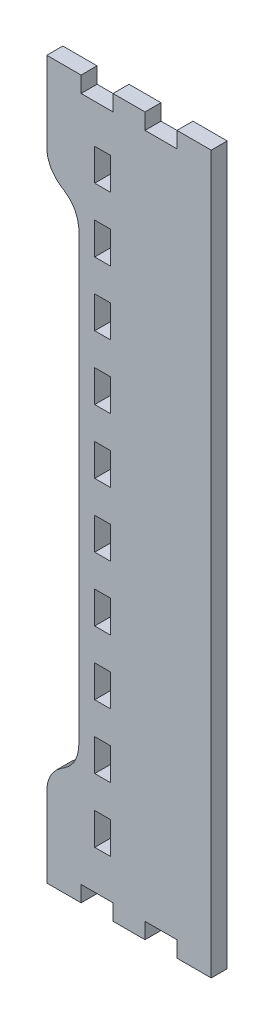
from build123d import *

# Parameters (mm, degrees)
BOSS_EXTRUDE1_DEPTH = 5.715


with BuildPart() as part:
    # Model → Boss-Extrude1 (new body)
    with BuildSketch(Plane.XY):
        Polygon((863.26218, 23.2006394), (875.52784, 23.2006394), (875.52784, 28.91536), (886.95784, 28.91536), (886.95784, 23.2006394), (898.38784, 23.2006394), (898.38784, 28.91536), (909.81784, 28.91536), (909.81784, 23.2006394), (922.08096, 23.2006394), (922.08096, 279.63114), (909.81784, 279.63114), (909.81784, 273.91614), (898.38784, 273.91614), (898.38784, 279.63114), (886.95784, 279.63114), (886.95784, 273.91614), (875.52784, 273.91614), (875.52784, 279.63114), (863.26218, 279.63114), (863.26218, 251.055124), (863.26218, 250.316746), (863.64826, 248.098056), (864.54234, 245.775988), (864.79126, 245.340378), (865.04272, 244.906546), (866.6099, 242.974368), (868.54284, 241.407696), (868.97718, 241.156744), (869.40898, 240.906046), (871.34446, 239.34039), (872.9091, 237.408466), (873.16056, 236.972856), (873.41202, 236.539024), (874.30356, 234.216956), (874.69472, 231.998266), (874.69472, 231.25811), (874.69472, 71.572628), (874.69218, 71.070978), (874.30356, 68.615306), (873.41202, 66.293238), (873.16056, 65.857882), (872.9091, 65.423796), (871.34446, 63.491872), (869.40898, 61.924946), (868.97718, 61.673994), (868.54284, 61.423296), (866.6099, 59.857894), (865.04272, 57.925716), (864.79126, 57.49036), (864.54234, 57.056274), (863.64826, 54.734206), (863.26218, 52.515516), (863.26218, 51.775868), align=None)
        Polygon((880.40718, 254.28448), (880.40718, 259.99948), (886.12218, 259.99948), (886.12218, 248.570496), (880.40718, 248.570496), align=None, mode=Mode.SUBTRACT)
        Polygon((880.40718, 231.424988), (880.40718, 237.141004), (886.12218, 237.141004), (886.12218, 225.710496), (880.40718, 225.710496), align=None, mode=Mode.SUBTRACT)
        Polygon((880.40718, 208.566004), (880.40718, 214.28075), (886.12218, 214.28075), (886.12218, 202.849988), (880.40718, 202.849988), align=None, mode=Mode.SUBTRACT)
        Polygon((880.40718, 185.70575), (880.40718, 191.420496), (886.12218, 191.420496), (886.12218, 179.991004), (880.40718, 179.991004), align=None, mode=Mode.SUBTRACT)
        Polygon((880.40718, 162.845496), (880.40718, 168.560496), (886.12218, 168.560496), (886.12218, 157.13075), (880.40718, 157.13075), align=None, mode=Mode.SUBTRACT)
        Polygon((880.40718, 139.985496), (880.40718, 145.699988), (886.12218, 145.699988), (886.12218, 134.270496), (880.40718, 134.270496), align=None, mode=Mode.SUBTRACT)
        Polygon((880.40718, 117.124988), (880.40718, 122.841004), (886.12218, 122.841004), (886.12218, 111.410496), (880.40718, 111.410496), align=None, mode=Mode.SUBTRACT)
        Polygon((880.40718, 94.266004), (880.40718, 99.98075), (886.12218, 99.98075), (886.12218, 88.549988), (880.40718, 88.549988), align=None, mode=Mode.SUBTRACT)
        Polygon((880.40718, 71.40575), (880.40718, 77.120496), (886.12218, 77.120496), (886.12218, 65.691004), (880.40718, 65.691004), align=None, mode=Mode.SUBTRACT)
        Polygon((880.40718, 48.545496), (880.40718, 54.260496), (886.12218, 54.260496), (886.12218, 42.83075), (880.40718, 42.83075), align=None, mode=Mode.SUBTRACT)
    extrude(amount=BOSS_EXTRUDE1_DEPTH)


solid = part.part
